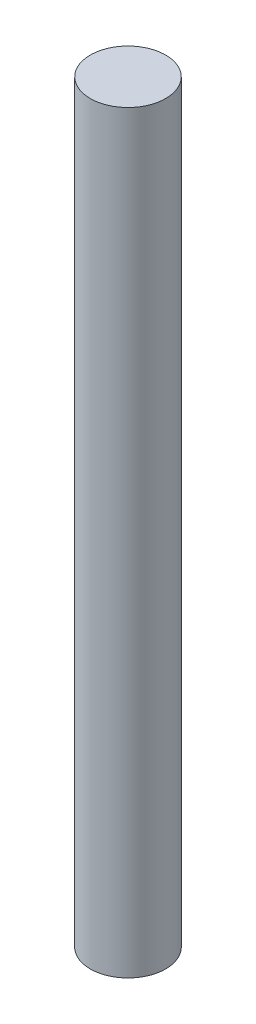
from build123d import *

# Parameters (mm, degrees)
SKETCH1_R           = 30
BOSS_EXTRUDE1_DEPTH = 600


with BuildPart() as part:
    # Sketch1 → Boss-Extrude1 (new body)
    with BuildSketch(Plane(origin=(0, 0, 0), x_dir=(1, 0, 0), z_dir=(0, 1, 0))):
        Circle(SKETCH1_R)
    extrude(amount=BOSS_EXTRUDE1_DEPTH)


solid = part.part
